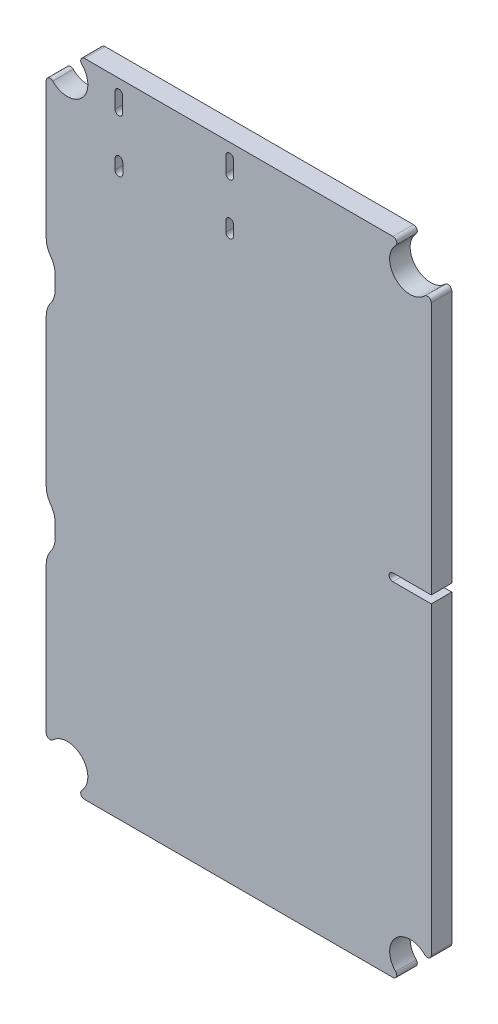
from build123d import *

# Parameters (mm, degrees)
BOARD_DEPTH        = 1.59936
CUT_EXTRUDE2_DEPTH = 2.59936
CUT_EXTRUDE3_DEPTH = 2.59936


with BuildPart() as part:
    # Sketch1 → Board (new body)
    with BuildSketch(Plane.XY):
        with BuildLine():
            Line((10, 12.987), (10, 24.35))
            ThreePointArc((10, 24.35), (10.089703362, 24.915270998), (10.35, 25.425))
            ThreePointArc((10.35, 25.425), (10.610296638, 25.934729002), (10.7, 26.5))
            Line((10.7, 26.5), (10.7, 27.5))
            ThreePointArc((10.7, 27.5), (10.610296638, 28.065270998), (10.35, 28.575))
            ThreePointArc((10.35, 28.575), (10.089703362, 29.084729002), (10, 29.65))
            Line((10, 29.65), (10, 41.1))
            ThreePointArc((10, 41.1), (10.089703362, 41.665270998), (10.35, 42.175))
            ThreePointArc((10.35, 42.175), (10.610296638, 42.684729002), (10.7, 43.25))
            Line((10.7, 43.25), (10.7, 44.25))
            ThreePointArc((10.7, 44.25), (10.610296638, 44.815270998), (10.35, 45.325))
            ThreePointArc((10.35, 45.325), (10.089703362, 45.834729002), (10, 46.4))
            Line((10, 46.4), (10, 57.01299))
            ThreePointArc((10, 57.01299), (10.185195521, 57.290150019), (10.51213, 57.22512))
            ThreePointArc((10.51213, 57.22512), (12.776257609, 57.223732391), (12.77487, 59.48786))
            ThreePointArc((12.77487, 59.48786), (12.709829188, 59.814802566), (12.987, 60))
            Line((12.987, 60), (37.01299, 60))
            ThreePointArc((37.01299, 60), (37.290150019, 59.814804479), (37.22512, 59.48787))
            ThreePointArc((37.22512, 59.48787), (37.223732391, 57.223742391), (39.48786, 57.22513))
            ThreePointArc((39.48786, 57.22513), (39.814807186, 57.290168899), (40, 57.01299))
            Line((40, 57.01299), (40, 12.987))
            ThreePointArc((40, 12.987), (39.814804479, 12.709839981), (39.48787, 12.77487))
            ThreePointArc((39.48787, 12.77487), (37.226515909, 12.773484091), (37.22513, 10.51213))
            ThreePointArc((37.22513, 10.51213), (37.290158106, 10.185190901), (37.01299, 10))
            Line((37.01299, 10), (12.987, 10))
            ThreePointArc((12.987, 10), (12.709839981, 10.185195521), (12.77487, 10.51213))
            ThreePointArc((12.77487, 10.51213), (12.773484091, 12.773484091), (10.51213, 12.77487))
            ThreePointArc((10.51213, 12.77487), (10.185195521, 12.709839981), (10, 12.987))
        make_face()
    extrude(amount=BOARD_DEPTH)

    # Sketch17 → Cut-Extrude2 (cut, through all)
    with BuildSketch(Plane.XY.offset(1.59936)):
        with BuildLine():
            Line((24.592, 58.964), (24.592, 57.764))
            ThreePointArc((24.592, 57.764), (24.292, 57.464), (23.992, 57.764))
            Line((23.992, 57.764), (23.992, 58.964))
            ThreePointArc((23.992, 58.964), (24.292, 59.264), (24.592, 58.964))
        make_face()
        with BuildLine():
            Line((24.592, 54.584), (24.592, 53.784))
            ThreePointArc((24.592, 53.784), (24.292, 53.484), (23.992, 53.784))
            Line((23.992, 53.784), (23.992, 54.584))
            ThreePointArc((23.992, 54.584), (24.292, 54.884), (24.592, 54.584))
        make_face()
        with BuildLine():
            Line((15.96453, 54.46518), (15.96453, 53.66518))
            ThreePointArc((15.96453, 53.66518), (15.66453, 53.36518), (15.36453, 53.66518))
            Line((15.36453, 53.66518), (15.36453, 54.46518))
            ThreePointArc((15.36453, 54.46518), (15.66453, 54.76518), (15.96453, 54.46518))
        make_face()
        with BuildLine():
            Line((15.956, 58.964), (15.956, 57.764))
            ThreePointArc((15.956, 57.764), (15.656, 57.464), (15.356, 57.764))
            Line((15.356, 57.764), (15.356, 58.964))
            ThreePointArc((15.356, 58.964), (15.656, 59.264), (15.956, 58.964))
        make_face()
    extrude(amount=-CUT_EXTRUDE2_DEPTH, mode=Mode.SUBTRACT)

    # Sketch18 → Cut-Extrude3 (cut, through all)
    with BuildSketch(Plane.XY.offset(1.59936)):
        with BuildLine():
            Line((37.015, 37.3), (41.715, 37.3))
            Line((41.715, 37.3), (41.715, 36.7))
            Line((41.715, 36.7), (37.015, 36.7))
            ThreePointArc((37.015, 36.7), (36.714999967, 37), (37.015, 37.3))
        make_face()
    extrude(amount=-CUT_EXTRUDE3_DEPTH, mode=Mode.SUBTRACT)


solid = part.part
